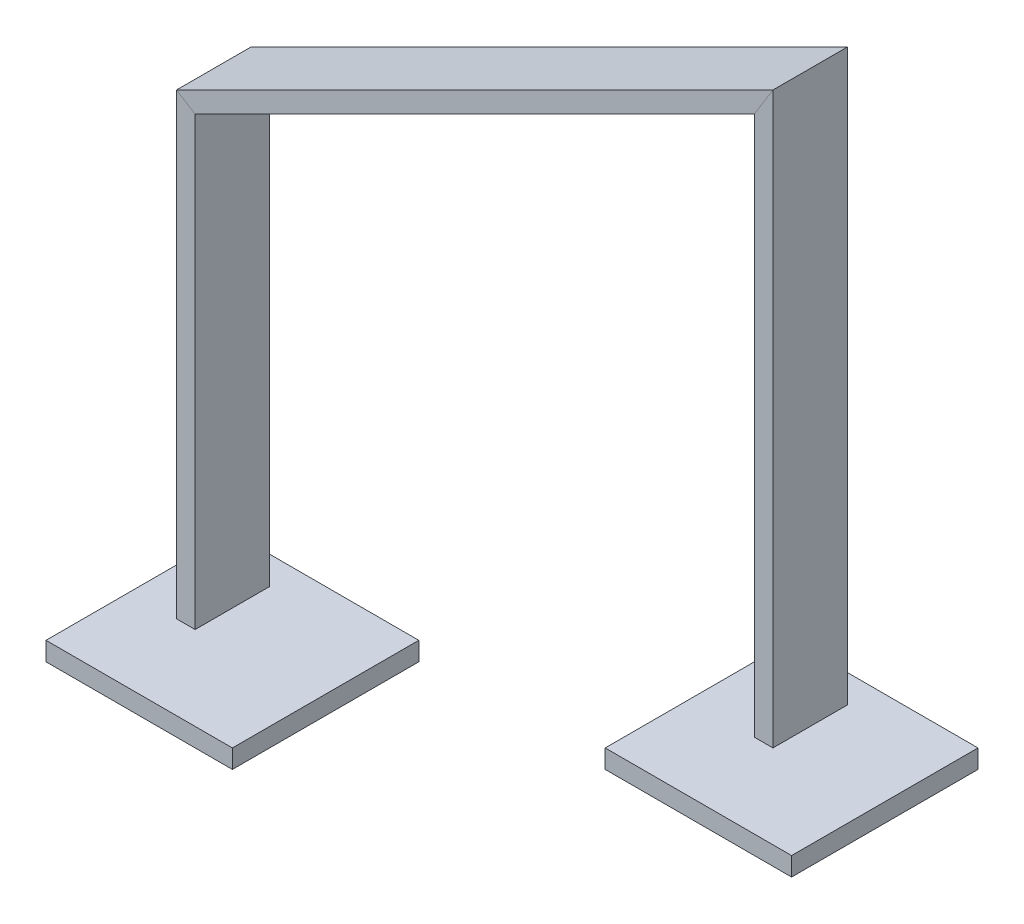
from build123d import *

# Parameters (mm, degrees)
SKIZZE1_W                       = 100
SKIZZE1_H                       = 100
AUFSATZ_LINEAR_AUSTRAGEN1_DEPTH = 10
SKIZZE2_W                       = 100
SKIZZE2_H                       = 10
AUFSATZ_LINEAR_AUSTRAGEN2_DEPTH = 50
SKIZZE5_W                       = 10
SKIZZE5_H                       = 40


with BuildPart() as part:
    # Skizze1 → Aufsatz-Linear austragen1 (new body)
    with BuildSketch(Plane(origin=(0, 0, 0), x_dir=(1, 0, 0), z_dir=(0, 1, 0))):
        with Locations((50, 0)):
            Rectangle(SKIZZE1_W, SKIZZE1_H)
    extrude(amount=AUFSATZ_LINEAR_AUSTRAGEN1_DEPTH)


with BuildPart() as body_2:
    # Skizze2 → Aufsatz-Linear austragen2 (new body, symmetric)
    with BuildSketch(Plane.XY):
        with Locations((350, 105)):
            Rectangle(SKIZZE2_W, SKIZZE2_H)
    extrude(amount=AUFSATZ_LINEAR_AUSTRAGEN2_DEPTH, both=True)


with BuildPart() as body_3:
    # Austragung2: sweep along a path in Skizze3
    with BuildLine(Plane.XY) as austragung2_path:
        Line((50, 25), (50, 264.508497187))
        Line((50, 264.508497187), (350, 414.508497187))
        Line((350, 414.508497187), (350, 125))
    # Skizze5 → Austragung2 (sweep)
    with BuildSketch(Plane(origin=(0, 25, 0), x_dir=(1, 0, 0), z_dir=(0, 1, 0))):
        with Locations((45, 0)):
            Rectangle(SKIZZE5_W, SKIZZE5_H)
    sweep(path=austragung2_path.line, transition=Transition.RIGHT)


solid = Compound([part.part, body_2.part, body_3.part])
